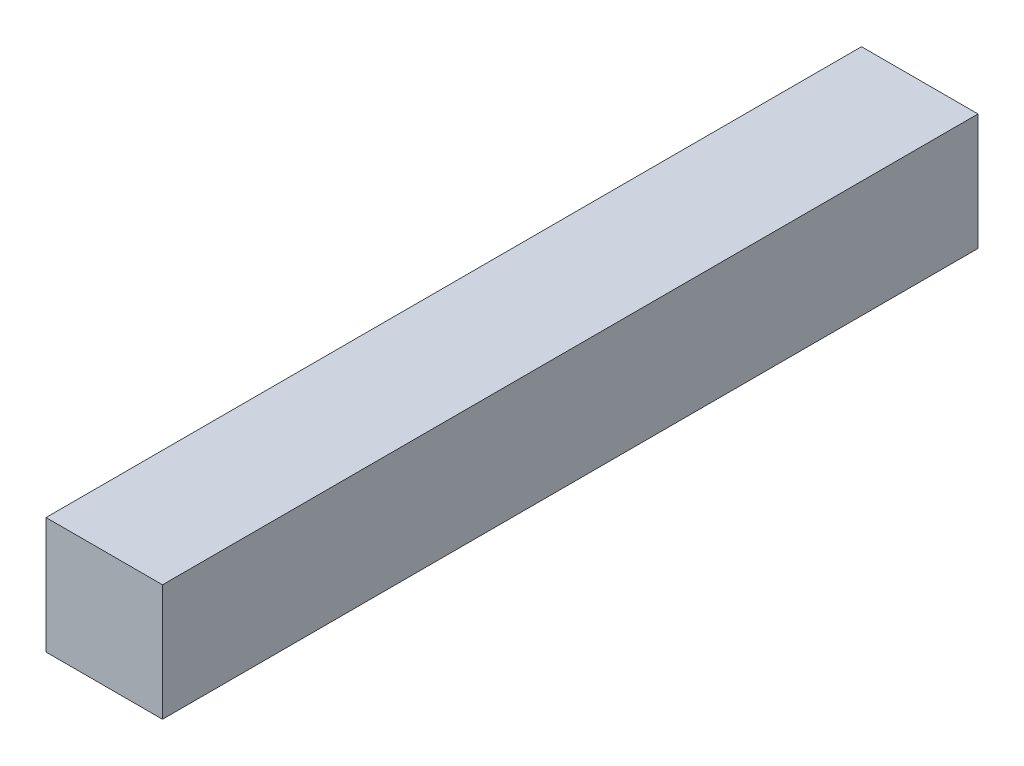
from build123d import *

# Parameters (mm, degrees)
SKETCH1_W           = 10
SKETCH1_H           = 10
BOSS_EXTRUDE1_DEPTH = 70


with BuildPart() as part:
    # Sketch1 → Boss-Extrude1 (new body)
    with BuildSketch(Plane.XY):
        with Locations((-44.617540212, 13.193098078)):
            Rectangle(SKETCH1_W, SKETCH1_H)
    extrude(amount=BOSS_EXTRUDE1_DEPTH)


solid = part.part
